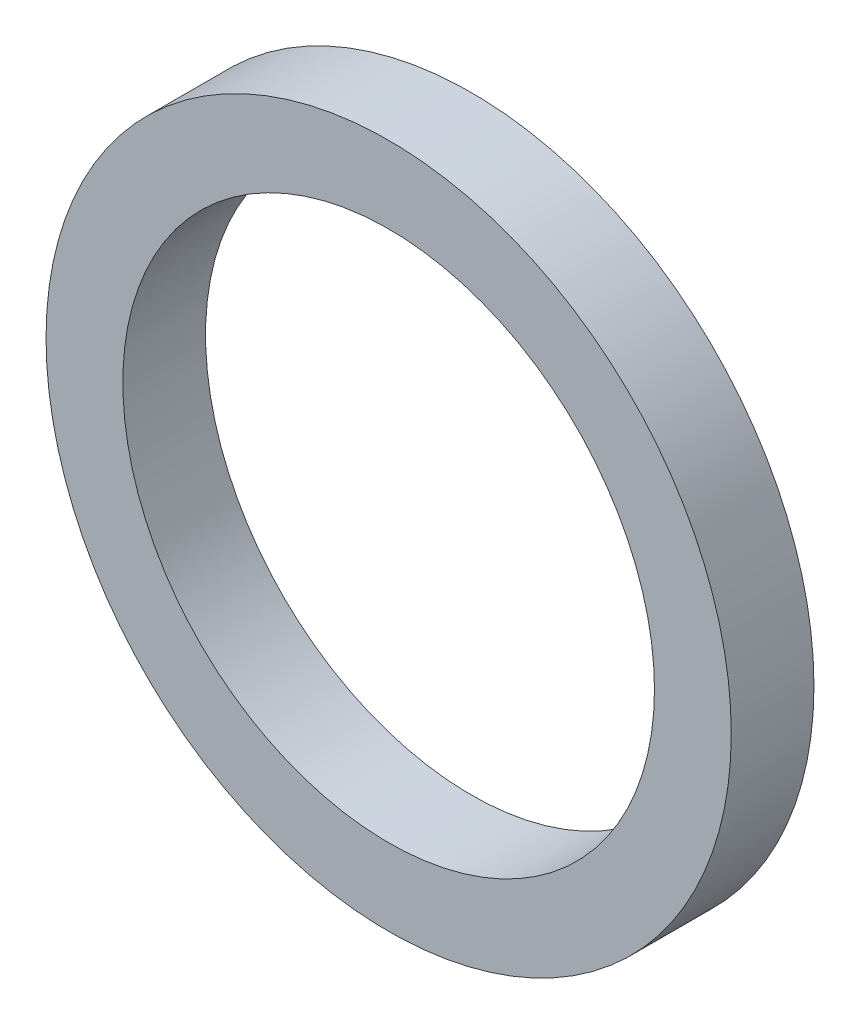
from build123d import *

# Parameters (mm, degrees)
SKETCH1_R           = 29
SKETCH1_R_2         = 22.5
BOSS_EXTRUDE1_DEPTH = 7


with BuildPart() as part:
    # Sketch1 → Boss-Extrude1 (new body)
    with BuildSketch(Plane.XY):
        Circle(SKETCH1_R)
        Circle(SKETCH1_R_2, mode=Mode.SUBTRACT)
    extrude(amount=BOSS_EXTRUDE1_DEPTH)


solid = part.part
